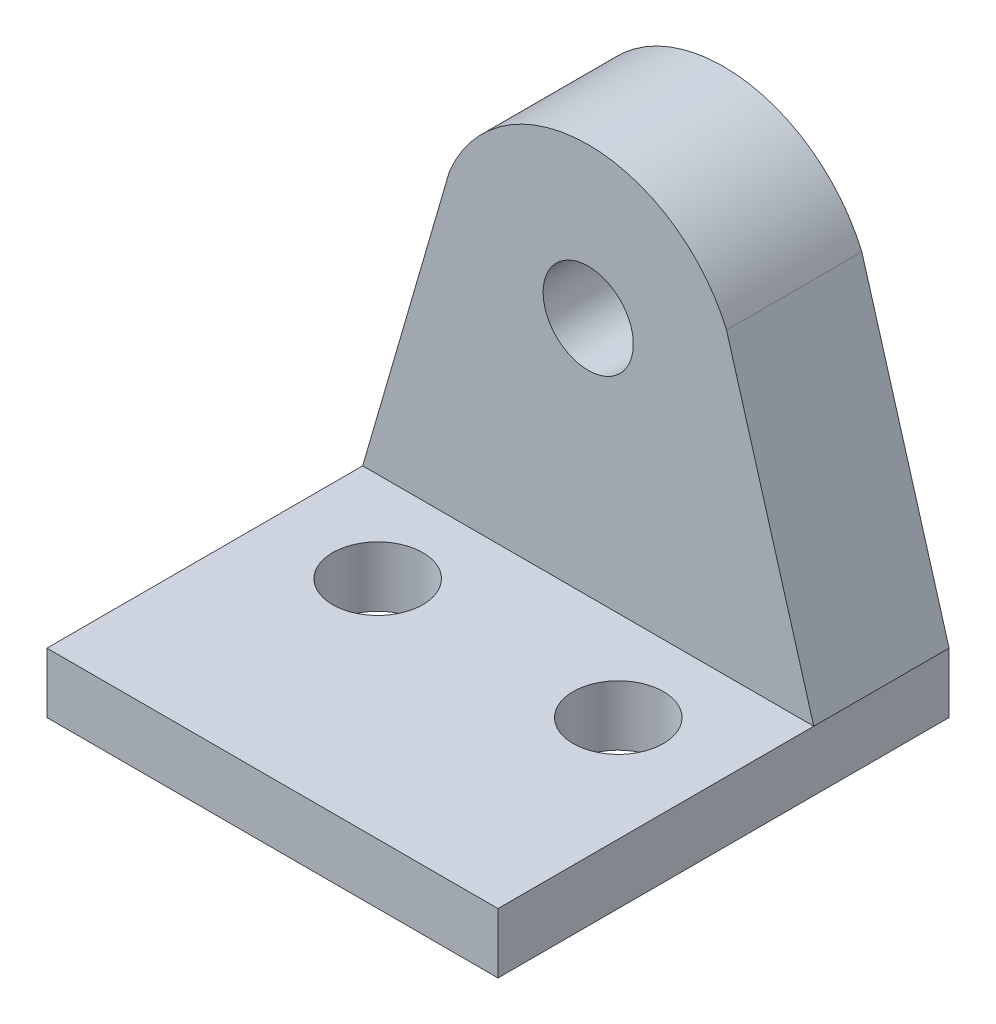
from build123d import *

# Parameters (mm, degrees)
SKETCH7_W           = 15
SKETCH7_H           = 7.5
BOSS_EXTRUDE2_DEPTH = 2
SKETCH8_R           = 1.5
BOSS_EXTRUDE3_DEPTH = 4.5
SKETCH9_R           = 1.5
CUT_EXTRUDE1_DEPTH  = 3


with BuildPart() as part:
    # Sketch7 → Boss-Extrude2 (new body)
    with BuildSketch(Plane(origin=(0, 0, 0), x_dir=(1, 0, 0), z_dir=(0, 1, 0))):
        with Locations((0, -3.75)):
            Rectangle(SKETCH7_W, SKETCH7_H)
    boss_extrude2 = extrude(amount=BOSS_EXTRUDE2_DEPTH)

    # Sketch8 → Boss-Extrude3 (add)
    with BuildSketch(Plane(origin=(0, 0, 0), x_dir=(-1, 0, 0), z_dir=(0, 0, -1))):
        with BuildLine():
            Line((-4.598991345, 11.961957852), (-7.5, 2))
            Line((-7.5, 2), (7.5, 2))
            Line((7.5, 2), (4.615024569, 11.923940807))
            ThreePointArc((4.615024569, 11.923940807), (0.020629833, 14.999957441), (-4.598991345, 11.961957852))
        make_face()
        with Locations((0, 10)):
            Circle(SKETCH8_R, mode=Mode.SUBTRACT)
    extrude(amount=-BOSS_EXTRUDE3_DEPTH)

    # Mirror1: Boss-Extrude2 across plane
    add(boss_extrude2.mirror(Plane(origin=(7.5, 2, 7.5), x_dir=(1, 0, 0), z_dir=(0, 0, -1))))

    # Sketch9 → Cut-Extrude1 (cut, through all)
    with BuildSketch(Plane(origin=(0, 2, 0), x_dir=(1, 0, 0), z_dir=(0, 1, 0))):
        with Locations((4, -7.5)):
            Circle(SKETCH9_R)
    cut_extrude1 = extrude(amount=-CUT_EXTRUDE1_DEPTH, mode=Mode.SUBTRACT)

    # Mirror2: Cut-Extrude1 across plane
    add(cut_extrude1.mirror(Plane(origin=(0, 0, 0), x_dir=(0, 0, 1), z_dir=(1, 0, 0))), mode=Mode.SUBTRACT)


solid = part.part
